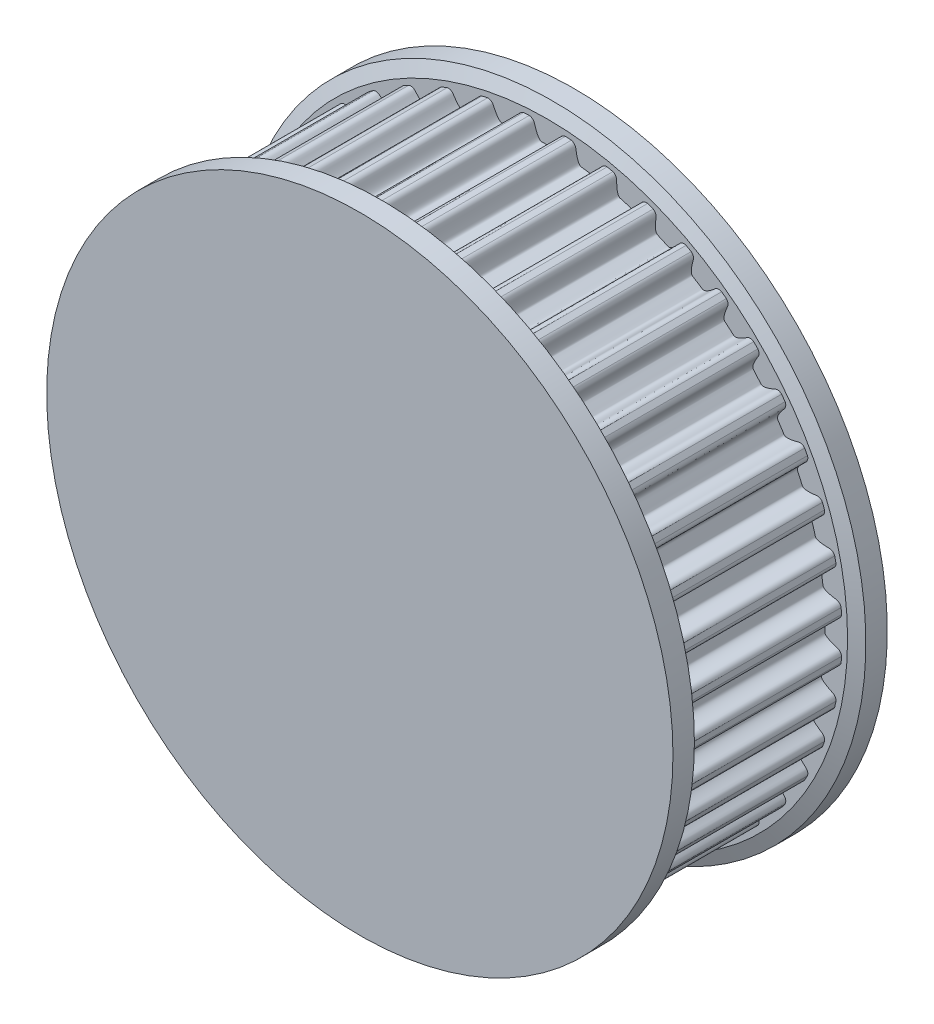
from build123d import *

# Parameters (mm, degrees)
TOOTHEXTRUDECUTGEARBELT01_DEPTH = 3.749999944
PATTERNGEARBELT01_COUNT         = 44
BOREREVOLVESKETCH_W             = 10.547999842
BOREREVOLVESKETCH_H             = 5
SKETCH1_W                       = 39.873641301
SKETCH1_H                       = 5.434831931
CUT_EXTRUDE1_DEPTH              = 15.76763477
CUT_EXTRUDE1_DEPTH_BACK         = 15.76763477
SKETCH2_R                       = 14.609188308
BOSS_EXTRUDE1_DEPTH             = 1
SKETCH3_R                       = 14.609188308
BOSS_EXTRUDE2_DEPTH             = 1
SKETCH4_R                       = 8.510864207
BOSS_EXTRUDE3_DEPTH             = 10


with BuildPart() as part:
    # SketchRevolveGearBelt01 → GearBelt01 (revolve)
    with BuildSketch(Plane(origin=(0, 0, 0), x_dir=(0, 0, -1), z_dir=(1, 0, 0))):
        Polygon((5.273999921, 0), (5.273999921, 12.505634804), (4.511999932, 12.505634804), (4.511999932, 13.85406356), (4.769626867, 14.476029999), (4.065630673, 14.76763477), (3.749999944, 14.005634782), (3.749999944, 13.749518966), (-3.749999944, 13.749518966), (-3.749999944, 14.005634782), (-4.065630673, 14.76763477), (-4.769626867, 14.476029999), (-4.511999932, 13.85406356), (-4.511999932, 12.505634804), (-5.273999921, 12.505634804), (-5.273999921, 0), align=None)
    revolve(axis=Axis((0, 0, 0), (0, 0, -1)))

    # SketchToothGearBelt01 → ToothExtrudeCutGearBelt01 (cut, symmetric)
    with BuildSketch(Plane.XY):
        with BuildLine():
            ThreePointArc((13.724144264, 0.861407831), (13.751151197, 0), (13.724144264, -0.861407831))
            add(Edge.make_bspline(
                [(13.724144264, -0.861407831), (13.724134967, -0.84414242), (13.721589278, -0.818247512), (13.713254143, -0.784696294), (13.704592599, -0.760257552), (13.693602128, -0.736773845), (13.680386419, -0.714466416), (13.66506992, -0.69354572), (13.647797254, -0.674208074), (13.628730184, -0.656638861), (13.60805219, -0.640991924), (13.585943998, -0.627458503), (13.562666748, -0.616002738), (13.522728902, -0.601841447), (13.471854473, -0.586470271), (13.411813683, -0.567480817), (13.359364282, -0.549825759), (13.310084704, -0.532186881), (13.263980535, -0.514546572), (13.22104932, -0.496909288), (13.181290272, -0.479273964), (13.144701793, -0.461640694), (13.111281973, -0.444008949), (13.081028318, -0.426377751), (13.053937802, -0.408745201), (13.030006597, -0.391107907), (13.009231404, -0.373460068), (12.991607332, -0.355792311), (12.977140838, -0.33809054), (12.965820072, -0.320336691), (12.957734199, -0.302512788), (12.952693436, -0.28461649), (12.950492192, -0.250312541), (12.953674459, -0.199994192), (12.953818513, -0.1333067), (12.954587046, -0.066656855), (12.954701118, 0), (12.954587046, 0.066656855), (12.953818513, 0.1333067), (12.953674459, 0.199994192), (12.950492192, 0.250312541), (12.952693436, 0.28461649), (12.957734199, 0.302512788), (12.965820072, 0.320336691), (12.977140838, 0.33809054), (12.991607332, 0.355792311), (13.009231404, 0.373460068), (13.030006597, 0.391107907), (13.053937802, 0.408745201), (13.081028318, 0.426377751), (13.111281973, 0.444008949), (13.144701793, 0.461640694), (13.181290272, 0.479273964), (13.22104932, 0.496909288), (13.263980535, 0.514546572), (13.310084704, 0.532186881), (13.359364282, 0.549825759), (13.411813683, 0.567480817), (13.471854473, 0.586470271), (13.522728902, 0.601841447), (13.562666748, 0.616002738), (13.585943998, 0.627458503), (13.60805219, 0.640991924), (13.628730184, 0.656638861), (13.647797254, 0.674208074), (13.66506992, 0.69354572), (13.680386419, 0.714466416), (13.693602128, 0.736773845), (13.704592599, 0.760257552), (13.713254143, 0.784696294), (13.721589278, 0.818247512), (13.724134967, 0.84414242), (13.724144264, 0.861407831)],
                knots=[0, 0, 0, 0, 0.019761428, 0.029642142, 0.039522856, 0.04940357, 0.059284284, 0.069164998, 0.079045712, 0.088926426, 0.09880714, 0.108687854, 0.118568568, 0.128449283, 0.157158434, 0.1794303, 0.200549338, 0.220522672, 0.239358723, 0.257067536, 0.273661203, 0.289154426, 0.303565278, 0.316916227, 0.329235541, 0.340559216, 0.350933619, 0.360419047, 0.369094352, 0.377062476, 0.384455955, 0.391440121, 0.398210357, 0.423676614, 0.449117743, 0.474558871, 0.5, 0.525441129, 0.550882257, 0.576323386, 0.601789643, 0.608559879, 0.615544045, 0.622937524, 0.630905648, 0.639580953, 0.649066381, 0.659440784, 0.670764459, 0.683083773, 0.696434722, 0.710845574, 0.726338797, 0.742932464, 0.760641277, 0.779477328, 0.799450662, 0.8205697, 0.842841566, 0.871550717, 0.881431432, 0.891312146, 0.90119286, 0.911073574, 0.920954288, 0.930835002, 0.940715716, 0.95059643, 0.960477144, 0.970357858, 0.980238572, 1, 1, 1, 1], degree=3))
        make_face()
    toothextrudecutgearbelt01 = extrude(amount=TOOTHEXTRUDECUTGEARBELT01_DEPTH, both=True, mode=Mode.SUBTRACT)

    # PatternGearBelt01: ToothExtrudeCutGearBelt01 ×44 about axis
    patterngearbelt01_axis = Axis((0, 0, 55), (0, 0, -1))
    for i in range(1, PATTERNGEARBELT01_COUNT):
        add(toothextrudecutgearbelt01.rotate(patterngearbelt01_axis, i * 360 / PATTERNGEARBELT01_COUNT), mode=Mode.SUBTRACT)

    # BoreRevolveSketch → BoreRevolveCut (revolve, cut)
    with BuildSketch(Plane(origin=(0, 0, 0), x_dir=(0, 0, -1), z_dir=(1, 0, 0))):
        with Locations((0, 2.5)):
            Rectangle(BOREREVOLVESKETCH_W, BOREREVOLVESKETCH_H)
    revolve(axis=Axis((0, 0, 0), (0, 0, -1)), mode=Mode.SUBTRACT)

    # Sketch1 → Cut-Extrude1 (cut, two sides)
    with BuildSketch(Plane(origin=(0, 0, 0), x_dir=(1, 0, 0), z_dir=(0, 1, 0))) as cut_extrude1_sk:
        with Locations((-1.293461133, 6.717415965)):
            Rectangle(SKETCH1_W, SKETCH1_H)
        with Locations((-1.293461133, -6.717415965)):
            Rectangle(SKETCH1_W, SKETCH1_H)
    extrude(amount=CUT_EXTRUDE1_DEPTH, mode=Mode.SUBTRACT)
    extrude(cut_extrude1_sk.sketch, amount=-CUT_EXTRUDE1_DEPTH_BACK, mode=Mode.SUBTRACT)

    # Sketch2 → Boss-Extrude1 (add)
    with BuildSketch(Plane.XY.offset(4)):
        Circle(SKETCH2_R)
    extrude(amount=BOSS_EXTRUDE1_DEPTH)

    # Sketch3 → Boss-Extrude2 (add)
    with BuildSketch(Plane(origin=(0, 0, -4), x_dir=(-1, 0, 0), z_dir=(0, 0, -1))):
        Circle(SKETCH3_R)
    extrude(amount=BOSS_EXTRUDE2_DEPTH)

    # Sketch4 → Boss-Extrude3 (add)
    with BuildSketch(Plane.XY.offset(5)):
        Circle(SKETCH4_R)
    extrude(amount=-BOSS_EXTRUDE3_DEPTH)


solid = part.part
